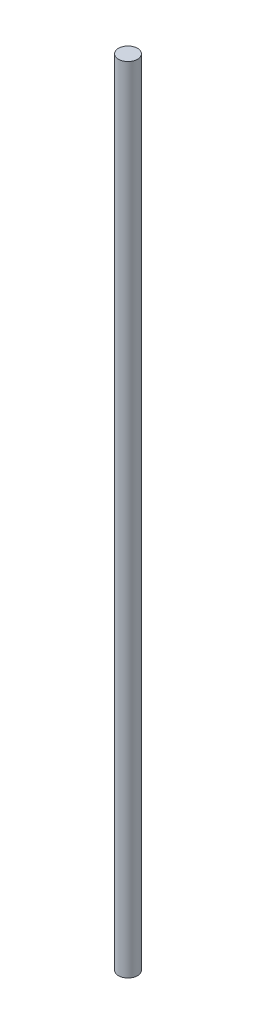
from build123d import *

# Parameters (mm, degrees)
SKETCH1_R           = 3
BOSS_EXTRUDE1_DEPTH = 250


with BuildPart() as part:
    # Sketch1 → Boss-Extrude1 (new body)
    with BuildSketch(Plane(origin=(0, 0, 0), x_dir=(1, 0, 0), z_dir=(0, 1, 0))):
        Circle(SKETCH1_R)
    extrude(amount=BOSS_EXTRUDE1_DEPTH)


solid = part.part
